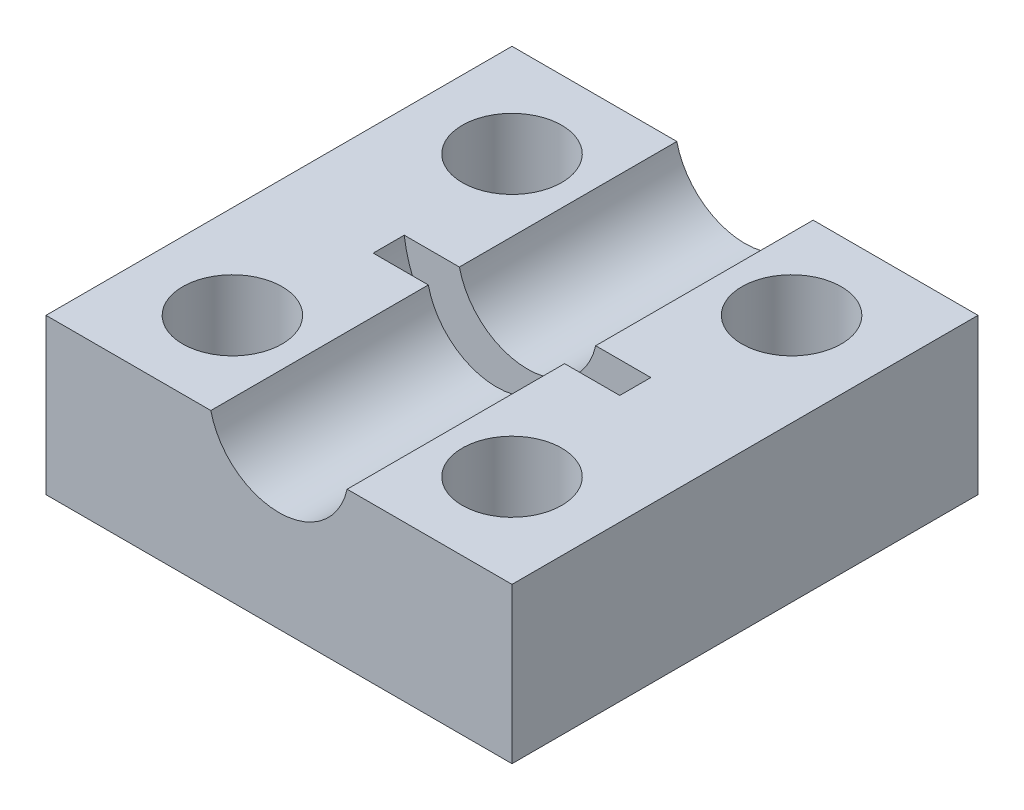
from build123d import *

# Parameters (mm, degrees)
SKIZZE1_W                       = 15
SKIZZE1_H                       = 15
SKIZZE1_R                       = 1.6
AUFSATZ_LINEAR_AUSTRAGEN1_DEPTH = 5
SKIZZE2_R                       = 2.25
SCHNITT_LINEAR_AUSTRAGEN1_DEPTH = 16
SKIZZE3_R                       = 4
SCHNITT_LINEAR_AUSTRAGEN2_DEPTH = 1


with BuildPart() as part:
    # Skizze1 → Aufsatz-Linear austragen1 (new body)
    with BuildSketch(Plane(origin=(0, 0, 0), x_dir=(1, 0, 0), z_dir=(0, 1, 0))):
        Rectangle(SKIZZE1_W, SKIZZE1_H)
        with Locations((-4.5, 4.5)):
            Circle(SKIZZE1_R, mode=Mode.SUBTRACT)
        with Locations((-4.5, -4.5)):
            Circle(SKIZZE1_R, mode=Mode.SUBTRACT)
        with Locations((4.5, -4.5)):
            Circle(SKIZZE1_R, mode=Mode.SUBTRACT)
        with Locations((4.5, 4.5)):
            Circle(SKIZZE1_R, mode=Mode.SUBTRACT)
    extrude(amount=AUFSATZ_LINEAR_AUSTRAGEN1_DEPTH)

    # Skizze2 → Schnitt-Linear austragen1 (cut, through all)
    with BuildSketch(Plane.XY.offset(7.5)):
        with Locations((0, 5.5)):
            Circle(SKIZZE2_R)
    extrude(amount=-SCHNITT_LINEAR_AUSTRAGEN1_DEPTH, mode=Mode.SUBTRACT)

    # Skizze3 → Schnitt-Linear austragen2 (cut)
    with BuildSketch(Plane.XY.offset(0.5)):
        with Locations((0, 5.5)):
            Circle(SKIZZE3_R)
    extrude(amount=-SCHNITT_LINEAR_AUSTRAGEN2_DEPTH, mode=Mode.SUBTRACT)


solid = part.part
